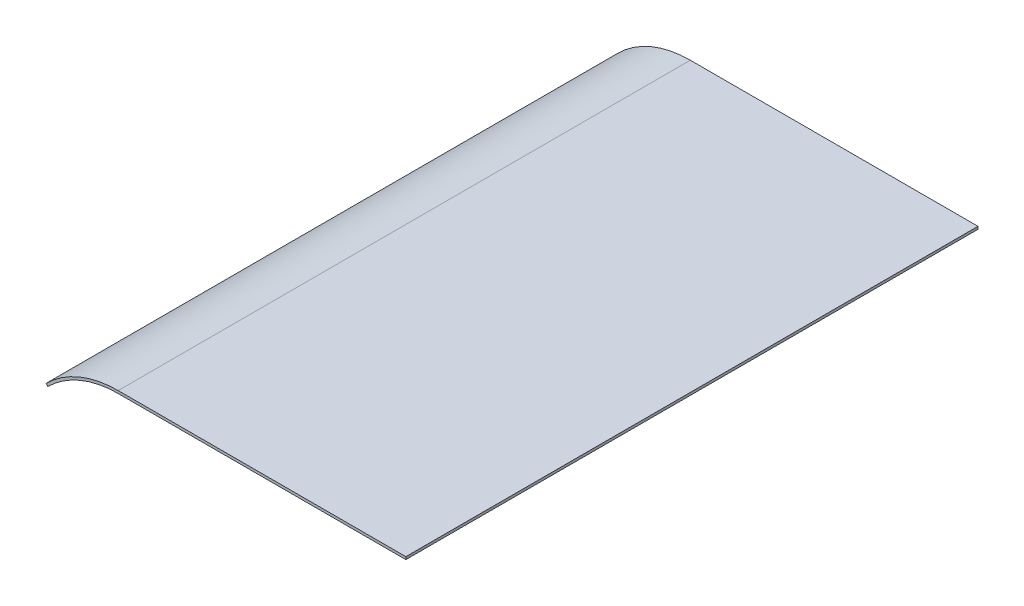
from build123d import *

# Parameters (mm, degrees)
EXTRUDE_THIN1_DEPTH = 165.1


with BuildPart() as part:
    # Sketch1 → Extrude-Thin1 (new body, symmetric)
    with BuildSketch(Plane.XY):
        with BuildLine():
            Line((-418.175, 963.93), (-584.2, 963.93))
            ThreePointArc((-584.2, 963.93), (-606.742034443, 959.446110563), (-625.852248486, 946.677073774))
            Line((-625.852248486, 946.677073774), (-624.791588314, 945.616413602))
            ThreePointArc((-624.791588314, 945.616413602), (-606.168009294, 958.060291265), (-584.2, 962.43))
            Line((-584.2, 962.43), (-418.175, 962.43))
            Line((-418.175, 962.43), (-418.175, 963.93))
        make_face()
    extrude(amount=EXTRUDE_THIN1_DEPTH, both=True)


solid = part.part
